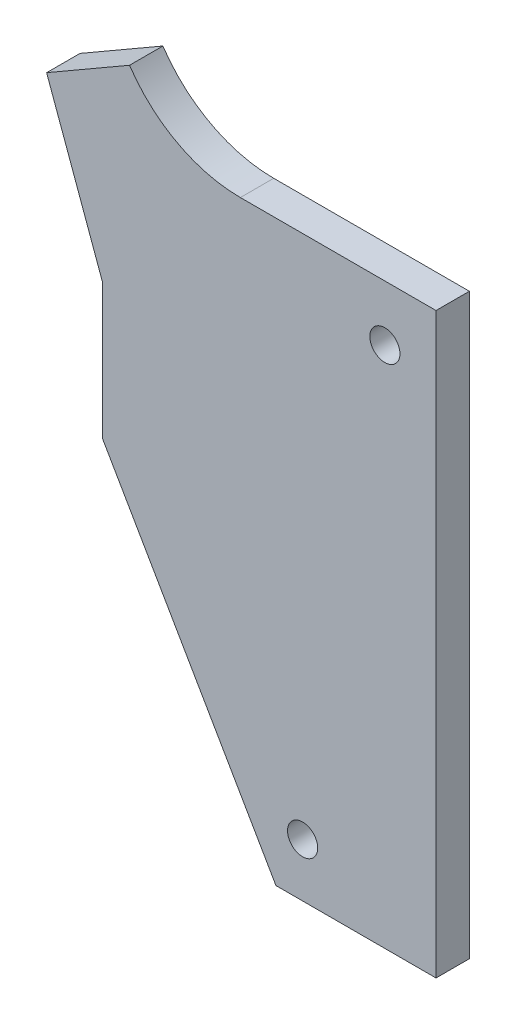
from build123d import *

# Parameters (mm, degrees)
BOSS_EXTRUDE1_DEPTH   = 4.7625
F_6_CLEARANCE_HOLE1_D = 4.3053


with BuildPart() as part:
    # Sketch1 → Boss-Extrude1 (new body)
    with BuildSketch(Plane.XY):
        with BuildLine():
            Line((-3103.698757178, 1002.345694712), (-3103.698757178, 1084.895694712))
            Line((-3103.698757178, 1084.895694712), (-3131.638757178, 1084.895694712))
            ThreePointArc((-3131.638757178, 1084.895694712), (-3140.608225903, 1087.139412233), (-3147.464838552, 1093.342032687))
            Line((-3147.464838552, 1093.342032687), (-3159.30564158, 1086.505741871))
            Line((-3159.30564158, 1086.505741871), (-3151.323757178, 1064.575694712))
            Line((-3151.323757178, 1064.575694712), (-3151.323757178, 1045.239932962))
            Line((-3151.323757178, 1045.239932962), (-3126.558757178, 1002.345694712))
            Line((-3126.558757178, 1002.345694712), (-3103.698757178, 1002.345694712))
        make_face()
    extrude(amount=BOSS_EXTRUDE1_DEPTH)

    # #6 Clearance Hole1 (through all)
    with Locations(Plane.XY.offset(4.7625)):
        with Locations((-3122.748757178, 1009.965694712), (-3111.001257178, 1076.958194712)):
            Hole(F_6_CLEARANCE_HOLE1_D / 2)


solid = part.part
